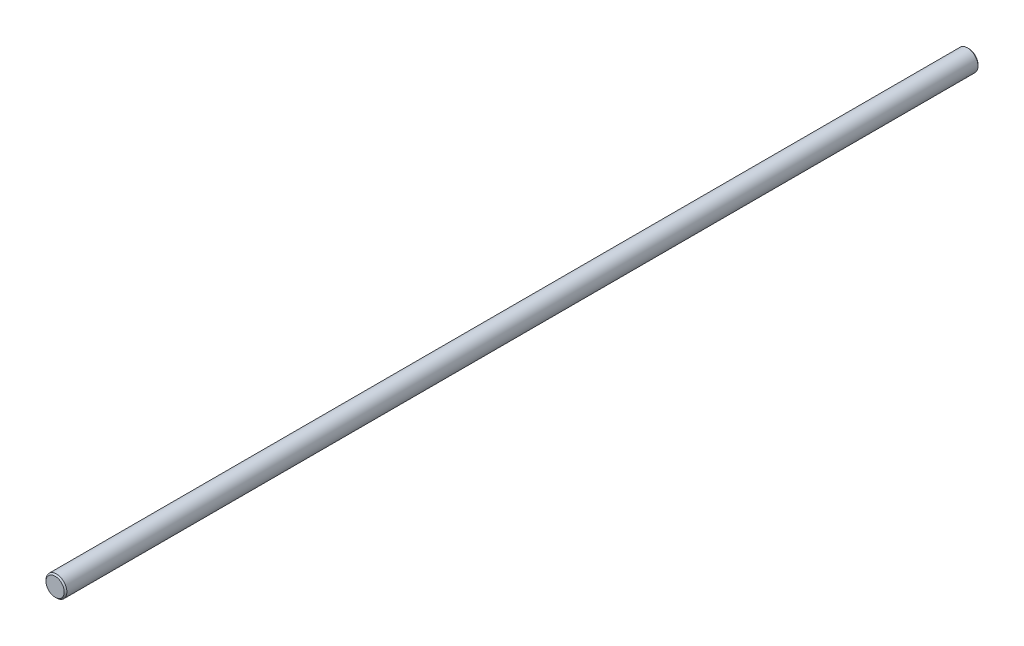
from build123d import *

# Parameters (mm, degrees)
SKETCH1_R           = 4
BOSS_EXTRUDE1_DEPTH = 350
CHAMFER1_SIZE       = 0.5


with BuildPart() as part:
    # Sketch1 → Boss-Extrude1 (new body)
    with BuildSketch(Plane.XY):
        Circle(SKETCH1_R)
    extrude(amount=-BOSS_EXTRUDE1_DEPTH)

    # Chamfer1
    chamfer1_edges = [part.edges().sort_by_distance(p)[0] for p in [
        (-4, 0, 0),
        (-4, 0, -350),
    ]]
    chamfer(chamfer1_edges, length=CHAMFER1_SIZE)


solid = part.part
